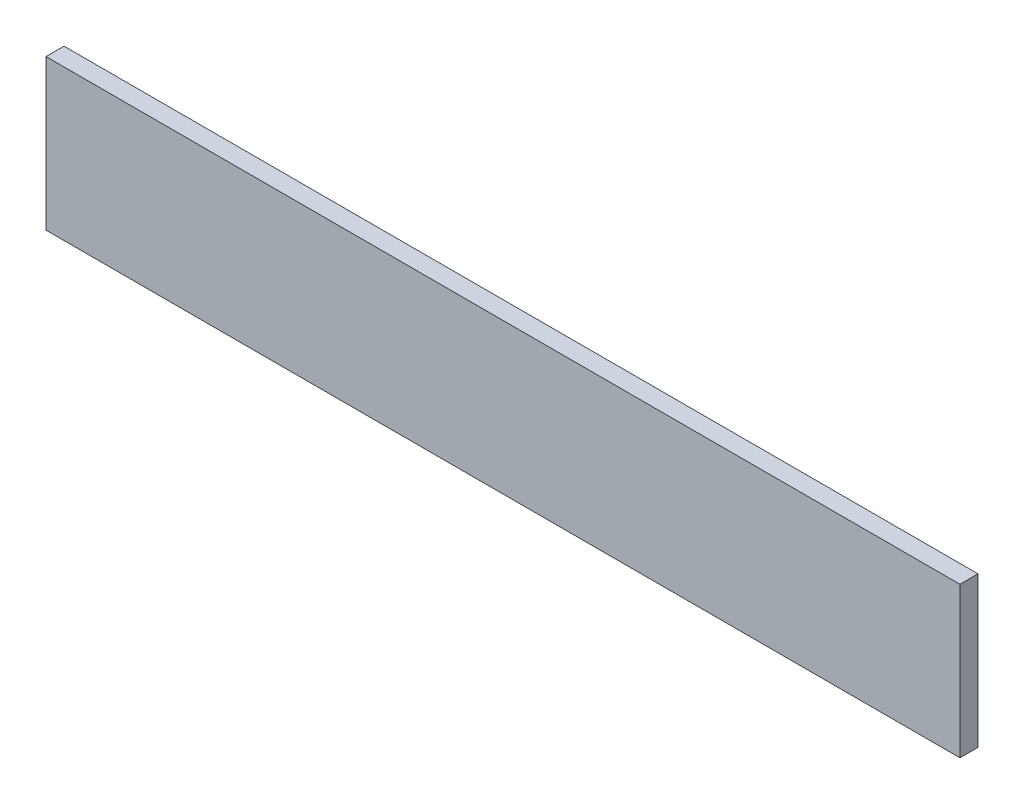
from build123d import *

# Parameters (mm, degrees)
SKETCH1_W           = 760
SKETCH1_H           = 125
BOSS_EXTRUDE1_DEPTH = 15


with BuildPart() as part:
    # Sketch1 → Boss-Extrude1 (new body)
    with BuildSketch(Plane.XY):
        Rectangle(SKETCH1_W, SKETCH1_H)
    extrude(amount=BOSS_EXTRUDE1_DEPTH)


solid = part.part
